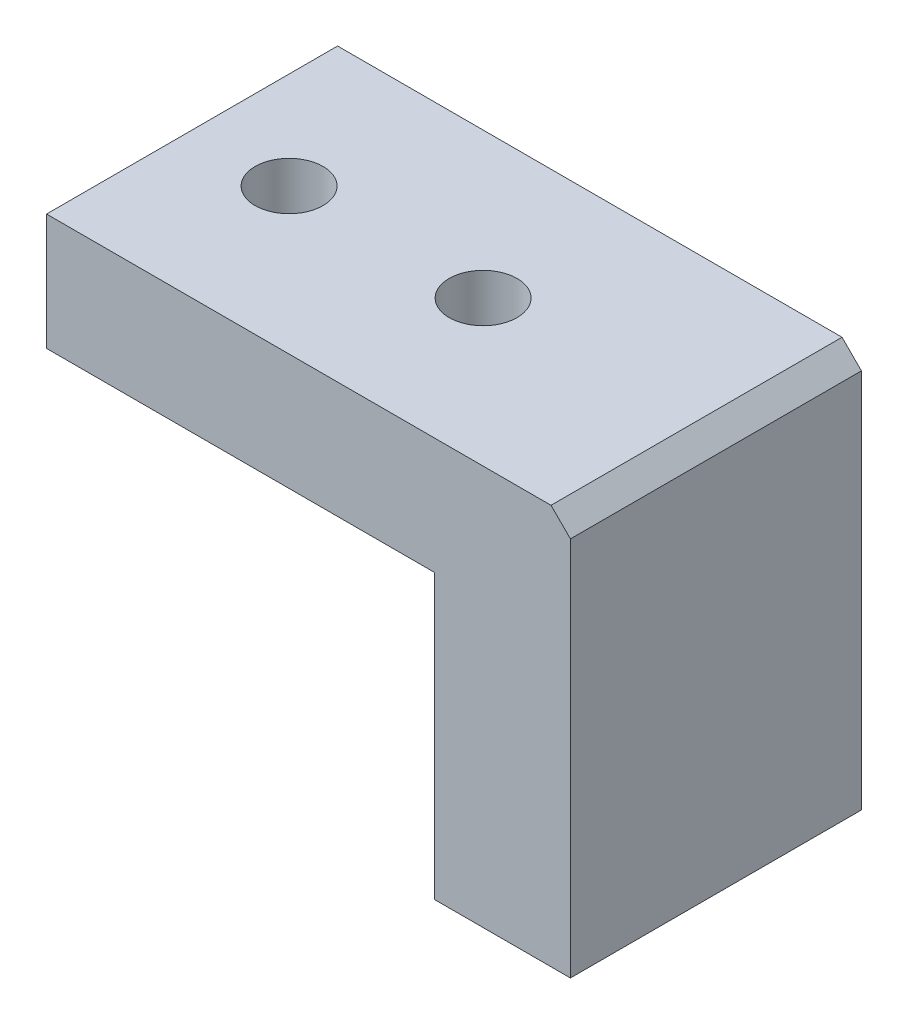
from build123d import *

# Parameters (mm, degrees)
BOSS_EXTRUDE1_DEPTH = 15
CHAMFER1_SIZE       = 1
SKETCH2_R           = 1.75
CUT_EXTRUDE1_DEPTH  = 7


with BuildPart() as part:
    # Sketch1 → Boss-Extrude1 (new body)
    with BuildSketch(Plane.XY):
        Polygon((-9.662207358, 6), (17.337792642, 6), (17.337792642, -14.6), (10.337792642, -14.6), (10.337792642, 0), (-9.662207358, 0), align=None)
    extrude(amount=BOSS_EXTRUDE1_DEPTH)

    # Chamfer1
    chamfer1_edges = [part.edges().sort_by_distance(p)[0] for p in [
        (17.337792642, 6, 7.5),
    ]]
    chamfer(chamfer1_edges, length=CHAMFER1_SIZE)

    # Sketch2 → Cut-Extrude1 (cut, through all)
    with BuildSketch(Plane.XZ):
        with Locations((-4.662207358, 7.5)):
            Circle(SKETCH2_R)
        with Locations((5.337792642, 7.5)):
            Circle(SKETCH2_R)
    extrude(amount=-CUT_EXTRUDE1_DEPTH, mode=Mode.SUBTRACT)


solid = part.part
